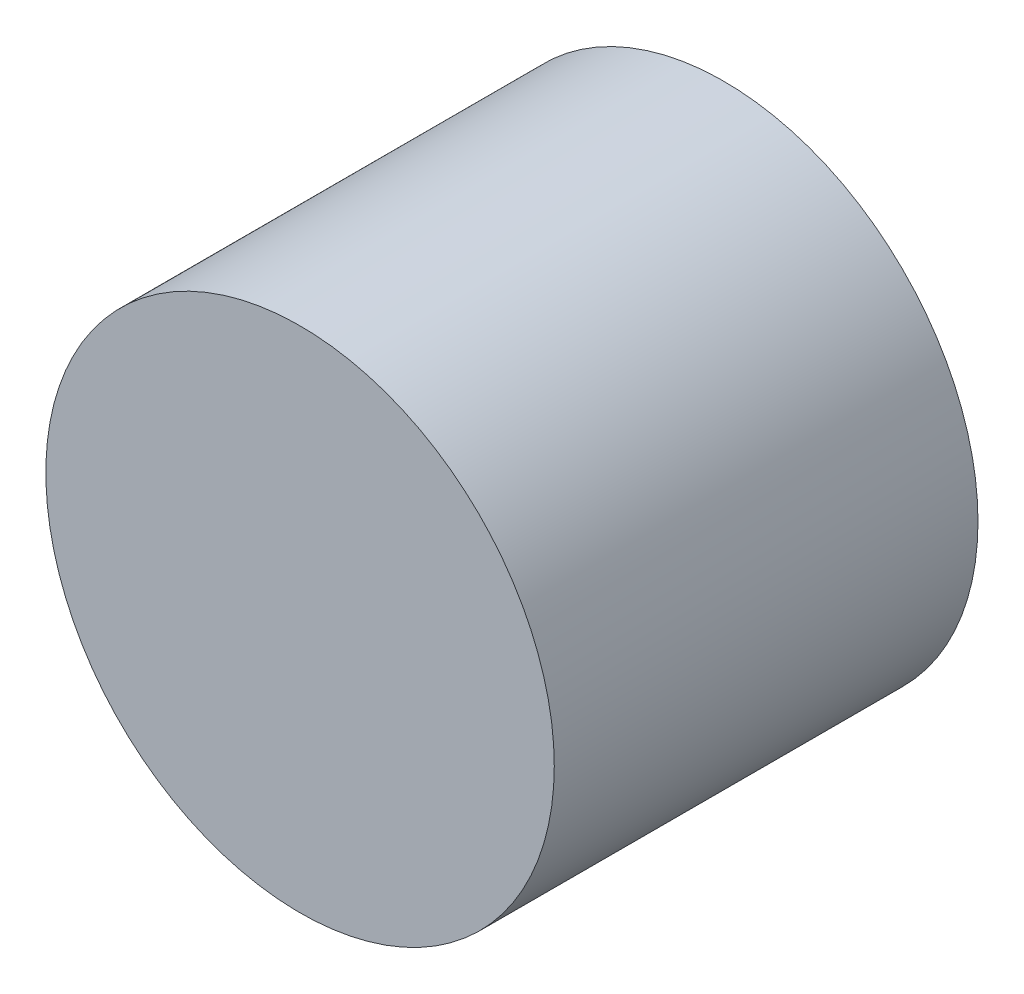
from build123d import *

# Parameters (mm, degrees)
SKETCH1_R           = 19.05
BOSS_EXTRUDE1_DEPTH = 31.75


with BuildPart() as part:
    # Sketch1 → Boss-Extrude1 (new body)
    with BuildSketch(Plane.XY):
        Circle(SKETCH1_R)
    extrude(amount=BOSS_EXTRUDE1_DEPTH)


solid = part.part
